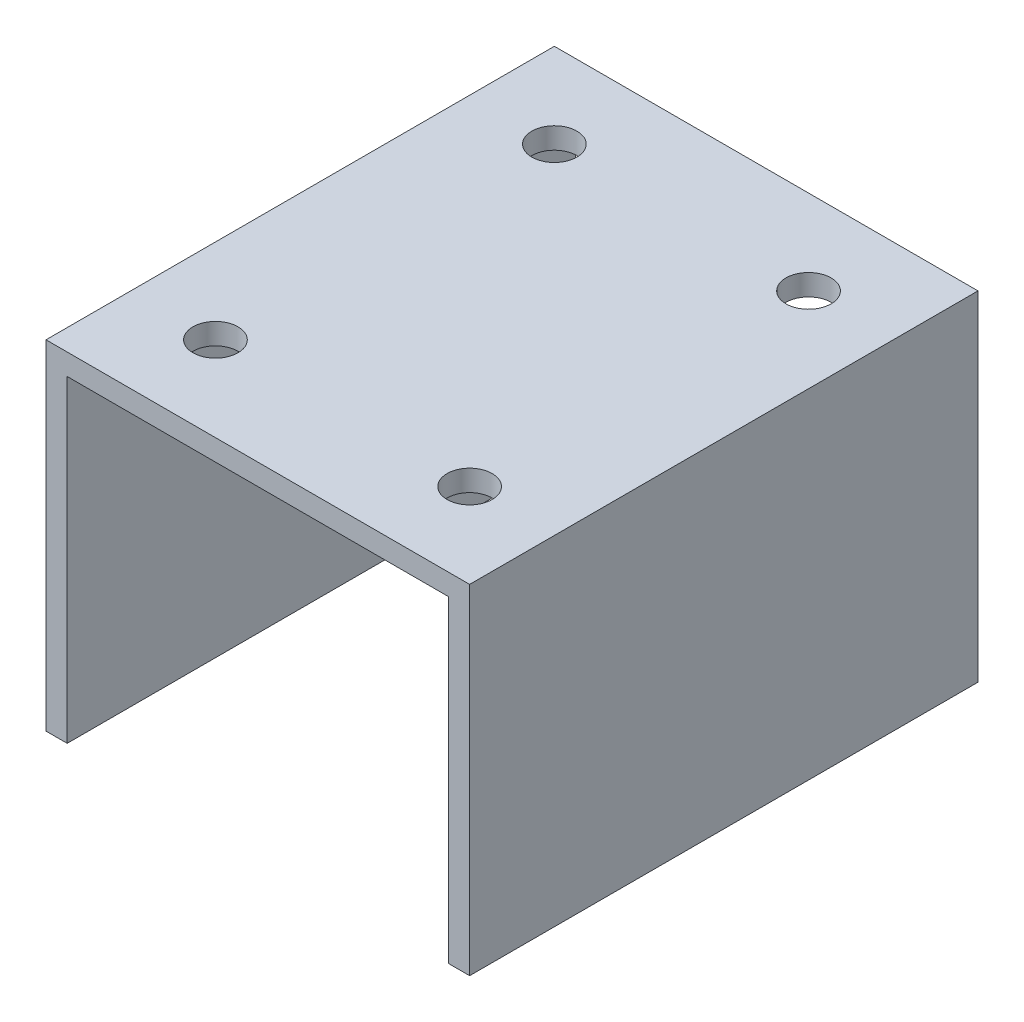
from build123d import *

# Parameters (mm, degrees)
BOSS_EXTRUDE1_DEPTH     = 38.1
F_1_4_CLEARANCE_HOLE1_D = 6.7564


with BuildPart() as part:
    # Sketch1 → Boss-Extrude1 (new body, symmetric)
    with BuildSketch(Plane.XY):
        Polygon((28.575, -47.625), (31.75, -47.625), (31.75, 3.175), (-31.75, 3.175), (-31.75, -47.625), (-28.575, -47.625), (-28.575, 0), (28.575, 0), align=None)
    extrude(amount=BOSS_EXTRUDE1_DEPTH, both=True)

    # 1/4 Clearance Hole1 (through all)
    with Locations(Plane(origin=(0, 3.175, 0), x_dir=(1, 0, 0), z_dir=(0, 1, 0))):
        with Locations((-19.05, 25.4), (19.05, 25.4), (19.05, -25.4), (-19.05, -25.4)):
            Hole(F_1_4_CLEARANCE_HOLE1_D / 2)


solid = part.part
